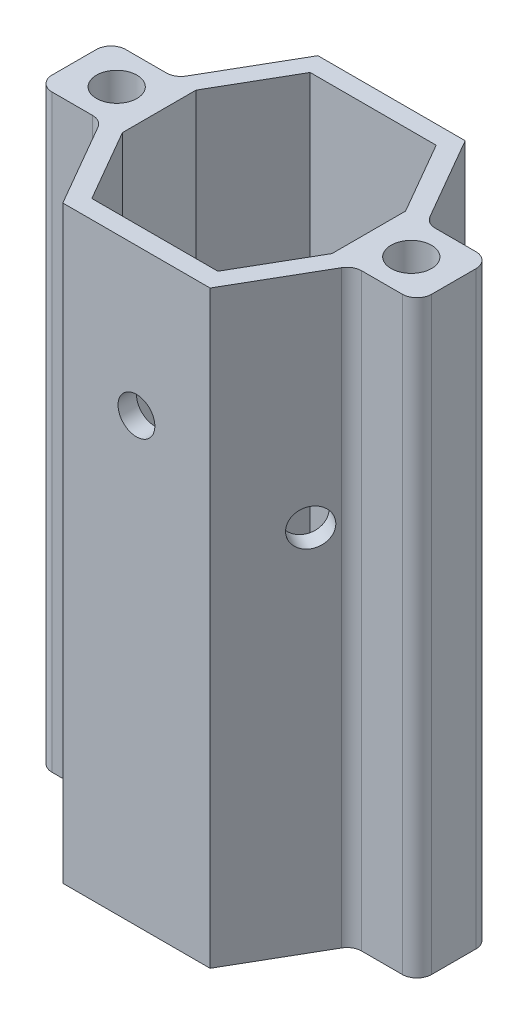
from build123d import *

# Parameters (mm, degrees)
BOSS_EXTRUDE1_DEPTH = 101.6
FILLET1_R           = 2.54
SKETCH9_R           = 1
CUT_EXTRUDE7_DEPTH  = 3.175
SKETCH11_R          = 3.175
CUT_EXTRUDE8_DEPTH  = 44.994090512
SKETCH12_R          = 3.175
CUT_EXTRUDE9_DEPTH  = 62.34261314
SKETCH13_R          = 3.175
CUT_EXTRUDE10_DEPTH = 62.34261314


with BuildPart() as part:
    # Sketch2 → Boss-Extrude1 (new body)
    with BuildSketch(Plane(origin=(0, 0, 0), x_dir=(1, 0, 0), z_dir=(0, 1, 0))):
        with BuildLine():
            Line((-23.65375, 3.024593723), (-21.733825791, 6.35))
            Line((-21.733825791, 6.35), (-32.732348419, 6.35))
            Line((-32.732348419, 6.35), (-32.732348419, -6.35))
            Line((-32.732348419, -6.35), (-21.733825791, -6.35))
            Line((-21.733825791, -6.35), (-23.65375, -3.024593723))
            ThreePointArc((-23.65375, -3.024593723), (-28.8925, 0), (-23.65375, 3.024593723))
        make_face()
        with BuildLine():
            Line((32.732348419, 6.35), (21.733825791, 6.35))
            Line((21.733825791, 6.35), (23.65375, 3.024593723))
            ThreePointArc((23.65375, 3.024593723), (27.14625, 3.024593723), (28.8925, 0))
            ThreePointArc((28.8925, 0), (27.14625, -3.024593723), (23.65375, -3.024593723))
            Line((23.65375, -3.024593723), (21.733825791, -6.35))
            Line((21.733825791, -6.35), (32.732348419, -6.35))
            Line((32.732348419, -6.35), (32.732348419, 6.35))
        make_face()
        Polygon((12.7, 21.997045256), (-12.7, 21.997045256), (-21.733825791, 6.35), (-18.067651581, 6.35), (-10.866912895, 18.822045256), (10.866912895, 18.822045256), (18.067651581, 6.35), (21.733825791, 6.35), align=None)
        Polygon((-10.866912895, -18.822045256), (-18.067651581, -6.35), (-21.733825791, -6.35), (-12.7, -21.997045256), (12.7, -21.997045256), (21.733825791, -6.35), (18.067651581, -6.35), (10.866912895, -18.822045256), align=None)
        with BuildLine():
            Line((-18.067651581, 6.35), (-21.733825791, 6.35))
            Line((-21.733825791, 6.35), (-23.65375, 3.024593723))
            ThreePointArc((-23.65375, 3.024593723), (-22.375406277, 1.74625), (-21.9075, 0))
            ThreePointArc((-21.9075, 0), (-22.375406277, -1.74625), (-23.65375, -3.024593723))
            Line((-23.65375, -3.024593723), (-21.733825791, -6.35))
            Line((-21.733825791, -6.35), (-18.067651581, -6.35))
            Line((-18.067651581, -6.35), (-21.733825791, 0))
            Line((-21.733825791, 0), (-18.067651581, 6.35))
        make_face()
        Polygon((-18.067651581, -6.35), (-18.067651581, 6.35), (-21.733825791, 0), align=None)
        with BuildLine():
            Line((23.65375, 3.024593723), (21.733825791, 6.35))
            Line((21.733825791, 6.35), (18.067651581, 6.35))
            Line((18.067651581, 6.35), (21.733825791, 0))
            Line((21.733825791, 0), (18.067651581, -6.35))
            Line((18.067651581, -6.35), (21.733825791, -6.35))
            Line((21.733825791, -6.35), (23.65375, -3.024593723))
            ThreePointArc((23.65375, -3.024593723), (21.9075, 0), (23.65375, 3.024593723))
        make_face()
        Polygon((21.733825791, 0), (18.067651581, 6.35), (18.067651581, -6.35), align=None)
    extrude(amount=BOSS_EXTRUDE1_DEPTH)

    # Fillet1
    fillet1_edges = [part.edges().sort_by_distance(p)[0] for p in [
        (21.733825791, 50.8, -6.35),
        (32.732348419, 50.8, -6.35),
        (32.732348419, 50.8, 6.35),
        (21.733825791, 50.8, 6.35),
        (-21.733825791, 50.8, 6.35),
        (-32.732348419, 50.8, 6.35),
        (-32.732348419, 50.8, -6.35),
        (-21.733825791, 50.8, -6.35),
    ]]
    fillet(fillet1_edges, radius=FILLET1_R)

    # Sketch9 → Cut-Extrude7 (cut)
    with BuildSketch(Plane.XY.offset(-21.997045256)):
        with Locations((-6.35, 6.35)):
            Circle(SKETCH9_R)
        with Locations((-6.35, 24.13)):
            Circle(SKETCH9_R)
        with Locations((6.35, 6.35)):
            Circle(SKETCH9_R)
        with Locations((6.35, 24.13)):
            Circle(SKETCH9_R)
        with Locations((-6.35, 49.53)):
            Circle(SKETCH9_R)
        with Locations((-6.35, 31.75)):
            Circle(SKETCH9_R)
        with Locations((6.35, 49.53)):
            Circle(SKETCH9_R)
        with Locations((6.35, 31.75)):
            Circle(SKETCH9_R)
    extrude(amount=CUT_EXTRUDE7_DEPTH, mode=Mode.SUBTRACT)

    # Sketch11 → Cut-Extrude8 (cut, through all)
    with BuildSketch(Plane(origin=(0, 0, -21.997045256), x_dir=(-1, 0, 0), z_dir=(0, 0, -1))):
        with Locations((0, 76.2)):
            Circle(SKETCH11_R)
    extrude(amount=-CUT_EXTRUDE8_DEPTH, mode=Mode.SUBTRACT)

    # Sketch12 → Cut-Extrude9 (cut, through all)
    with BuildSketch(Plane(origin=(-19.05, 0, -10.998522628), x_dir=(-0.5, 0, 0.866025404), z_dir=(-0.866025404, 0, -0.5))):
        with Locations((0, 63.5)):
            Circle(SKETCH12_R)
    extrude(amount=-CUT_EXTRUDE9_DEPTH, mode=Mode.SUBTRACT)

    # Sketch13 → Cut-Extrude10 (cut, through all)
    with BuildSketch(Plane(origin=(19.05, 0, -10.998522628), x_dir=(-0.5, 0, -0.866025404), z_dir=(0.866025404, 0, -0.5))):
        with Locations((0, 50.8)):
            Circle(SKETCH13_R)
    extrude(amount=-CUT_EXTRUDE10_DEPTH, mode=Mode.SUBTRACT)


solid = part.part
